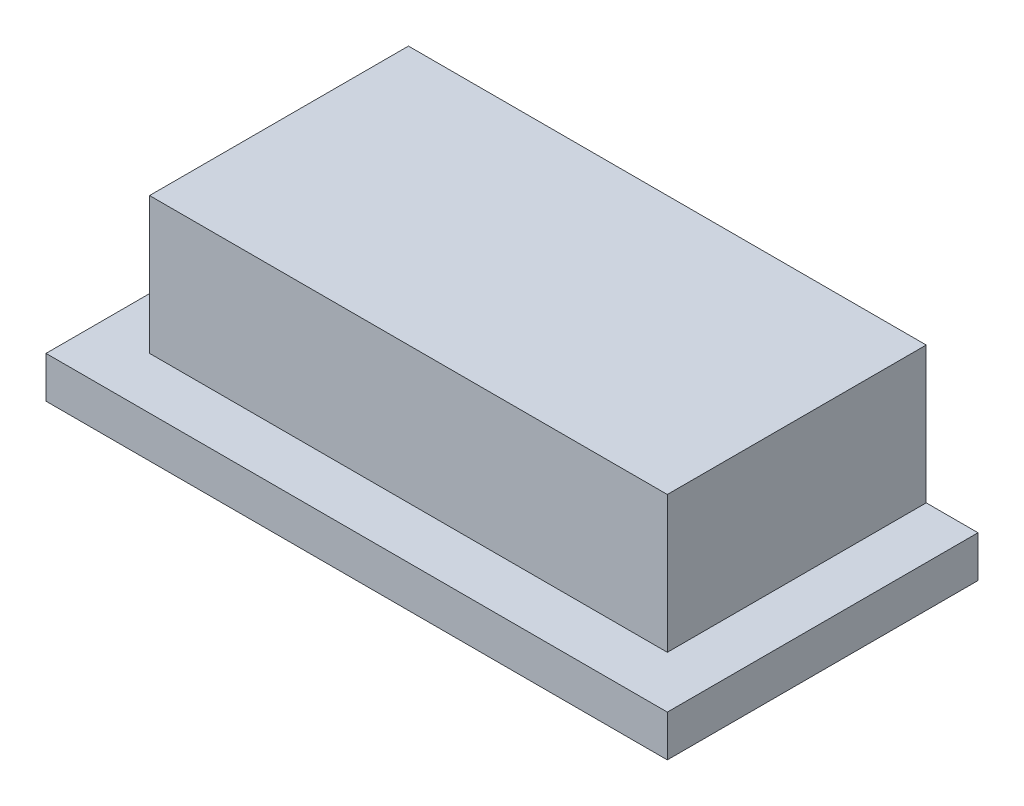
from build123d import *

# Parameters (mm, degrees)
SKETCH_1_W      = 600
SKETCH_1_H      = 300
EXTRUDE_1_DEPTH = 40
SKETCH_2_W      = 500
SKETCH_2_H      = 250
EXTRUDE_2_DEPTH = 132


with BuildPart() as part:
    # Эскиз1 → Бобышка-Вытянуть1 (new body)
    with BuildSketch(Plane(origin=(0, 0, 0), x_dir=(1, 0, 0), z_dir=(0, 1, 0))):
        with Locations((0, 47.243006581)):
            Rectangle(SKETCH_1_W, SKETCH_1_H)
    extrude(amount=EXTRUDE_1_DEPTH)

    # Эскиз2 → Бобышка-Вытянуть2 (add)
    with BuildSketch(Plane(origin=(0, 40, 0), x_dir=(1, 0, 0), z_dir=(0, 1, 0))):
        with Locations((0, 72.243006581)):
            Rectangle(SKETCH_2_W, SKETCH_2_H)
    extrude(amount=EXTRUDE_2_DEPTH)


solid = part.part
